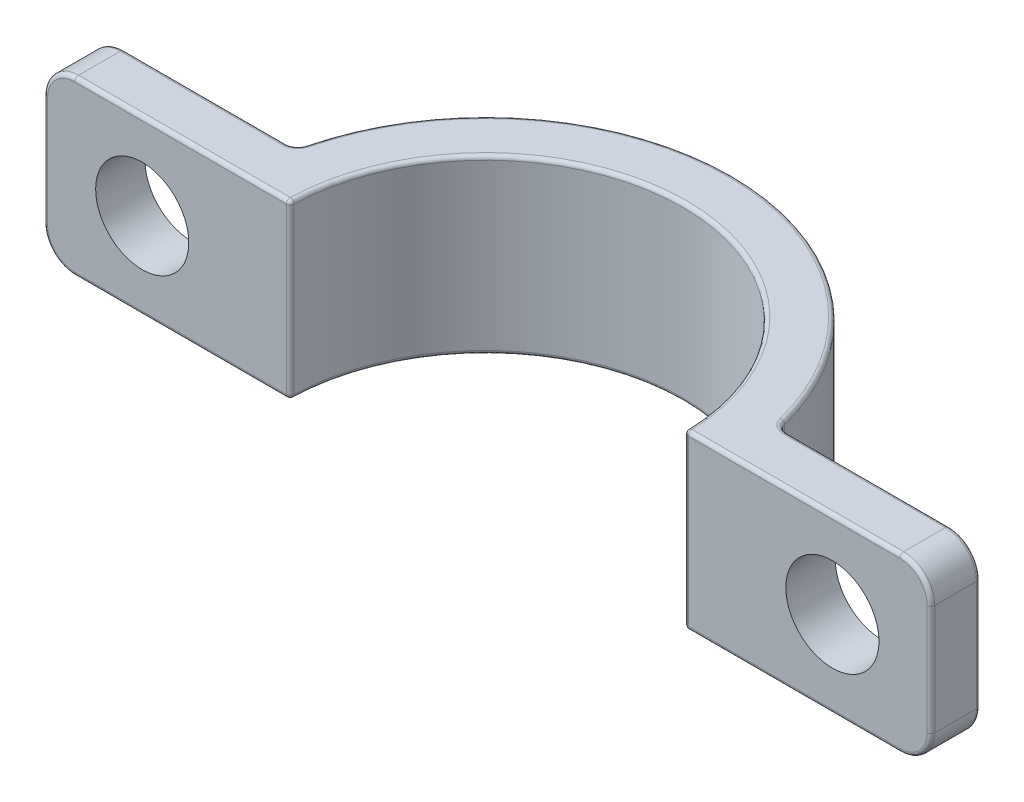
from build123d import *

# Parameters (mm, degrees)
DODANIE_WYCI_GNI_CIE1_DEPTH    = 11.11
OTWORY_USTALAJ_CE_6_0MM1_D     = 6
OTWORY_USTALAJ_CE_6_0MM1_DEPTH = 3.18
ZAOKR_GLENIE1_R                = 2
ZAOKR_GLENIE2_R                = 0.76
ZAOKR_GLENIE4_R                = 0.25


with BuildPart() as part:
    # Szkic1 → Dodanie-wyciągnięcie1 (new body)
    with BuildSketch(Plane(origin=(0, 0, 0), x_dir=(1, 0, 0), z_dir=(0, 1, 0))):
        with BuildLine():
            Line((-28.575, 0.113686746), (-12.699491144, 0.113686746))
            ThreePointArc((-12.699491144, 0.113686746), (0, 12.7), (12.699491144, 0.113686746))
            Line((12.699491144, 0.113686746), (28.575, 0.113686746))
            Line((28.575, 0.113686746), (28.575, 3.293686746))
            Line((28.575, 3.293686746), (15.53467179, 3.293686746))
            ThreePointArc((15.53467179, 3.293686746), (0, 15.88), (-15.53467179, 3.293686746))
            Line((-15.53467179, 3.293686746), (-28.575, 3.293686746))
            Line((-28.575, 3.293686746), (-28.575, 0.113686746))
        make_face()
    extrude(amount=DODANIE_WYCI_GNI_CIE1_DEPTH)

    # Otwory ustalające Ø6.0mm1
    with Locations(Plane(origin=(0, 0, -3.293686746), x_dir=(-1, 0, 0), z_dir=(0, 0, -1))):
        with Locations((-22.23, 5.56), (22.23, 5.56)):
            Hole(OTWORY_USTALAJ_CE_6_0MM1_D / 2, depth=OTWORY_USTALAJ_CE_6_0MM1_DEPTH)

    # Zaokrąglenie1
    zaokr_glenie1_edges = [part.edges().sort_by_distance(p)[0] for p in [
        (28.575, 0, -1.703686746),
        (-28.575, 11.11, -1.703686746),
        (28.575, 11.11, -1.703686746),
        (-28.575, 0, -1.703686746),
    ]]
    fillet(zaokr_glenie1_edges, radius=ZAOKR_GLENIE1_R)

    # Zaokrąglenie2
    zaokr_glenie2_edges = [part.edges().sort_by_distance(p)[0] for p in [
        (-15.53467179, 5.555, -3.293686746),
        (15.53467179, 5.555, -3.293686746),
    ]]
    fillet(zaokr_glenie2_edges, radius=ZAOKR_GLENIE2_R)

    # Zaokrąglenie4
    zaokr_glenie4_edges = [part.edges().sort_by_distance(p)[0] for p in [
        (19.637245572, 0, -0.113686746),
        (12.699491144, 5.555, -0.113686746),
        (-12.699491144, 5.555, -0.113686746),
        (0, 11.11, -12.7),
        (28.575, 5.555, -3.293686746),
        (28.575, 5.555, -0.113686746),
        (27.989213562, 10.524213562, -3.293686746),
        (27.989213562, 0.585786438, -3.293686746),
        (-19.637245572, 0, -0.113686746),
        (-21.356843588, 0, -3.293686746),
        (27.989213562, 10.524213562, -0.113686746),
        (27.989213562, 0.585786438, -0.113686746),
        (-21.356843588, 11.11, -3.293686746),
        (-19.637245572, 11.11, -0.113686746),
        (-28.575, 5.555, -0.113686746),
        (-28.575, 5.555, -3.293686746),
        (-27.989213562, 0.585786438, -3.293686746),
        (-27.989213562, 10.524213562, -3.293686746),
        (-27.989213562, 0.585786438, -0.113686746),
        (-27.989213562, 10.524213562, -0.113686746),
        (19.637245572, 11.11, -0.113686746),
        (0, 0, -15.88),
        (0, 11.11, -15.88),
        (21.356843588, 0, -3.293686746),
        (21.356843588, 11.11, -3.293686746),
        (-15.671306016, 0, -3.45439145),
        (-15.671306016, 11.11, -3.45439145),
        (15.671306016, 0, -3.45439145),
        (15.671306016, 11.11, -3.45439145),
        (0, 0, -12.7),
    ]]
    fillet(zaokr_glenie4_edges, radius=ZAOKR_GLENIE4_R)


solid = part.part
